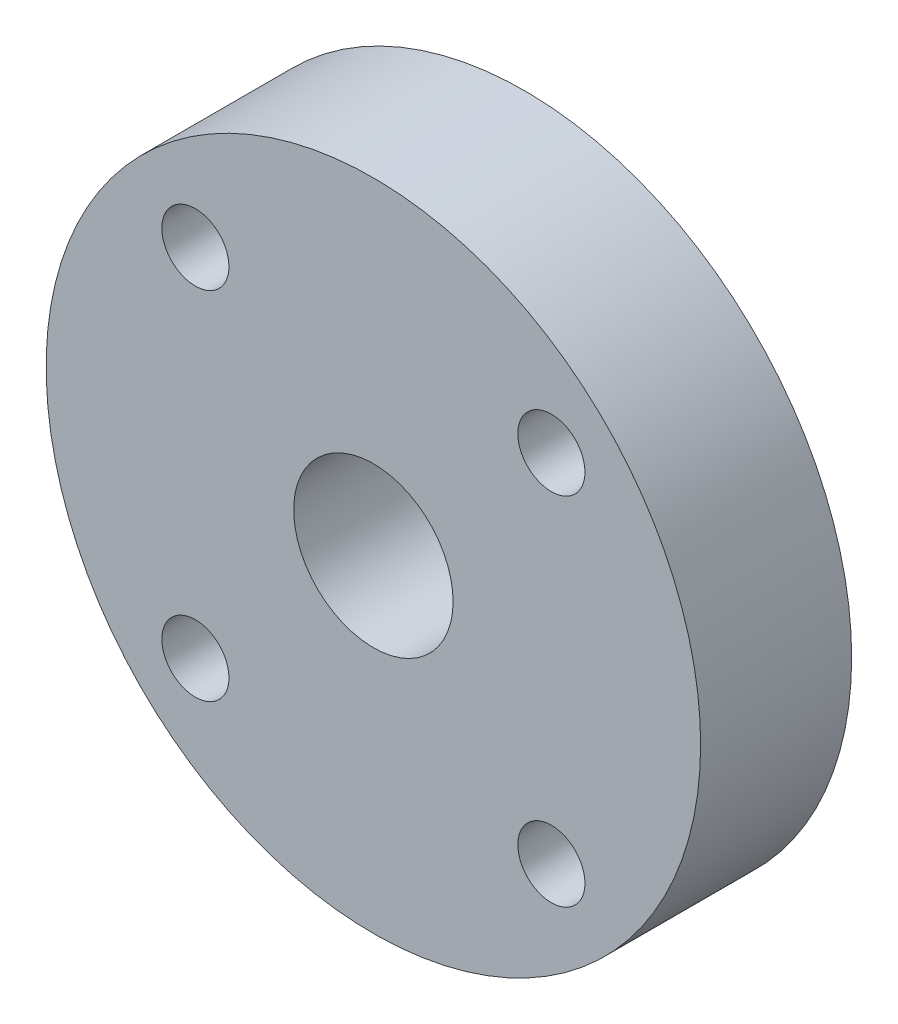
from build123d import *

# Parameters (mm, degrees)
SKETCH1_R           = 39
SKETCH1_R_2         = 4
SKETCH1_R_3         = 9.5
BOSS_EXTRUDE1_DEPTH = 18


with BuildPart() as part:
    # Sketch1 → Boss-Extrude1 (new body)
    with BuildSketch(Plane.XY):
        Circle(SKETCH1_R)
        with Locations((-21.213203436, 21.213203436)):
            Circle(SKETCH1_R_2, mode=Mode.SUBTRACT)
        with Locations((21.213203436, 21.213203436)):
            Circle(SKETCH1_R_2, mode=Mode.SUBTRACT)
        with Locations((21.213203436, -21.213203436)):
            Circle(SKETCH1_R_2, mode=Mode.SUBTRACT)
        with Locations((-21.213203436, -21.213203436)):
            Circle(SKETCH1_R_2, mode=Mode.SUBTRACT)
        Circle(SKETCH1_R_3, mode=Mode.SUBTRACT)
    extrude(amount=BOSS_EXTRUDE1_DEPTH)


solid = part.part
